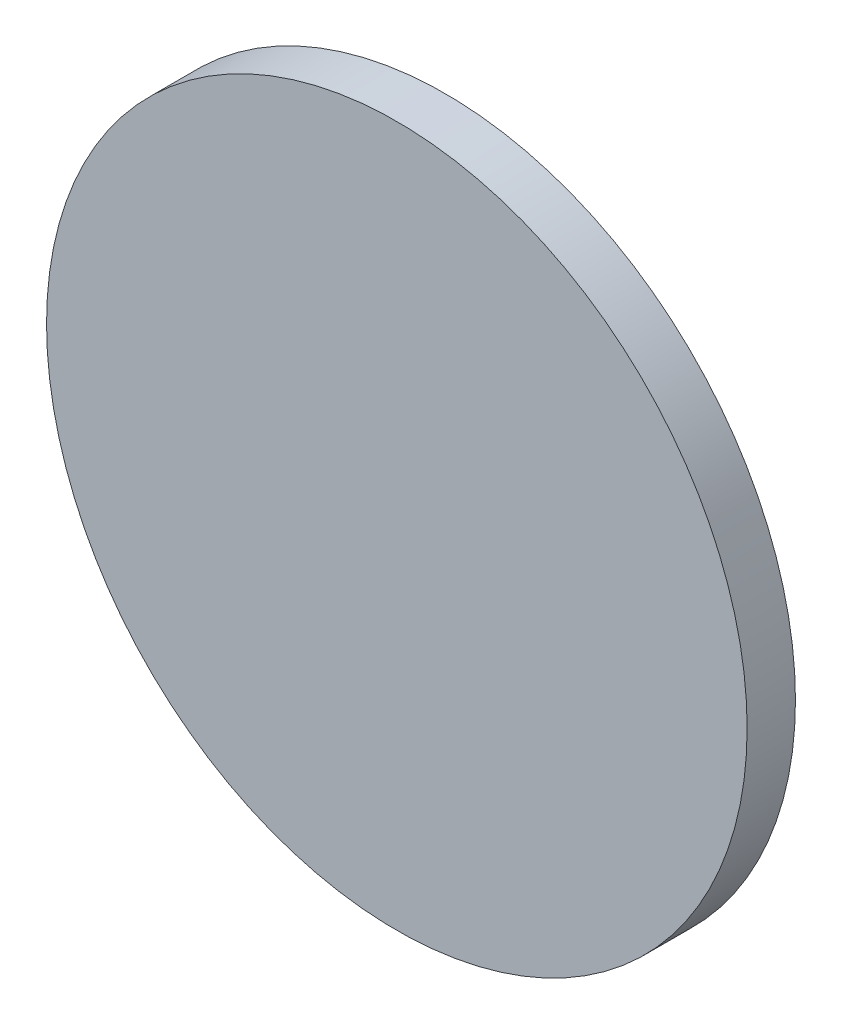
from build123d import *

# Parameters (mm, degrees)
SKETCH1_R           = 14.5
BOSS_EXTRUDE1_DEPTH = 2


with BuildPart() as part:
    # Sketch1 → Boss-Extrude1 (new body)
    with BuildSketch(Plane.XY):
        Circle(SKETCH1_R)
    extrude(amount=BOSS_EXTRUDE1_DEPTH)


solid = part.part
